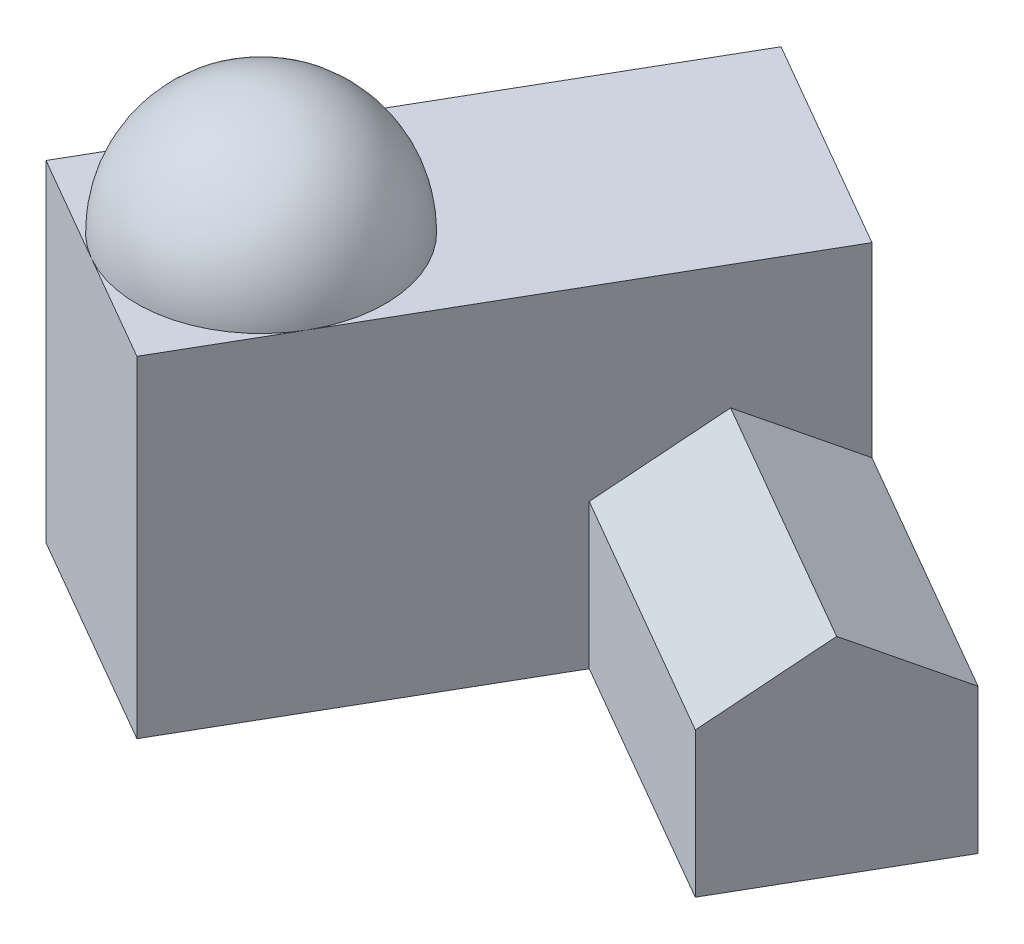
from build123d import *

# Parameters (mm, degrees)
MAIN_BUILDING_DEPTH       = 80
SMALL_BUILDING_DEPTH      = 35
SMALL_BUILDING_ROOF_DEPTH = 70


with BuildPart() as part:
    # Sketch1 → Main Building (new body)
    with BuildSketch(Plane(origin=(0, 0, 0), x_dir=(1, 0, 0), z_dir=(0, 1, 0))):
        Polygon((0, 0), (-65, -112.583302492), (-13.038475773, -142.583302492), (51.961524227, -30), align=None)
    extrude(amount=MAIN_BUILDING_DEPTH)

    # Sketch2 → Dome (revolve)
    with BuildSketch(Plane(origin=(0, 80, 0), x_dir=(-1, 0, 0), z_dir=(0, 1, 0))):
        with BuildLine():
            Line((24.019237886, 71.602540378), (24.019237886, 131.602540378))
            ThreePointArc((24.019237886, 131.602540378), (-5.980762114, 101.602540378), (24.019237886, 71.602540378))
        make_face()
    revolve(axis=Axis((-24.019237886, 80, 71.602540378), (0, 0, 1)))

    # Sketch3 → Small Building (add)
    with BuildSketch(Plane(origin=(0, 0, 0), x_dir=(1, 0, 0), z_dir=(0, 1, 0))):
        Polygon((51.961524227, -30), (112.583302492, -65), (87.583302492, -108.301270189), (26.961524227, -73.301270189), align=None)
    extrude(amount=SMALL_BUILDING_DEPTH)

    # Sketch4 → Small Building Roof (add)
    with BuildSketch(Plane(origin=(112.583302492, 0, 65), x_dir=(0.5, 0, -0.866025404), z_dir=(0.866025404, 0, 0.5))):
        Polygon((0, 35), (-50, 35), (-25, 50), align=None)
    extrude(amount=-SMALL_BUILDING_ROOF_DEPTH)


solid = part.part
